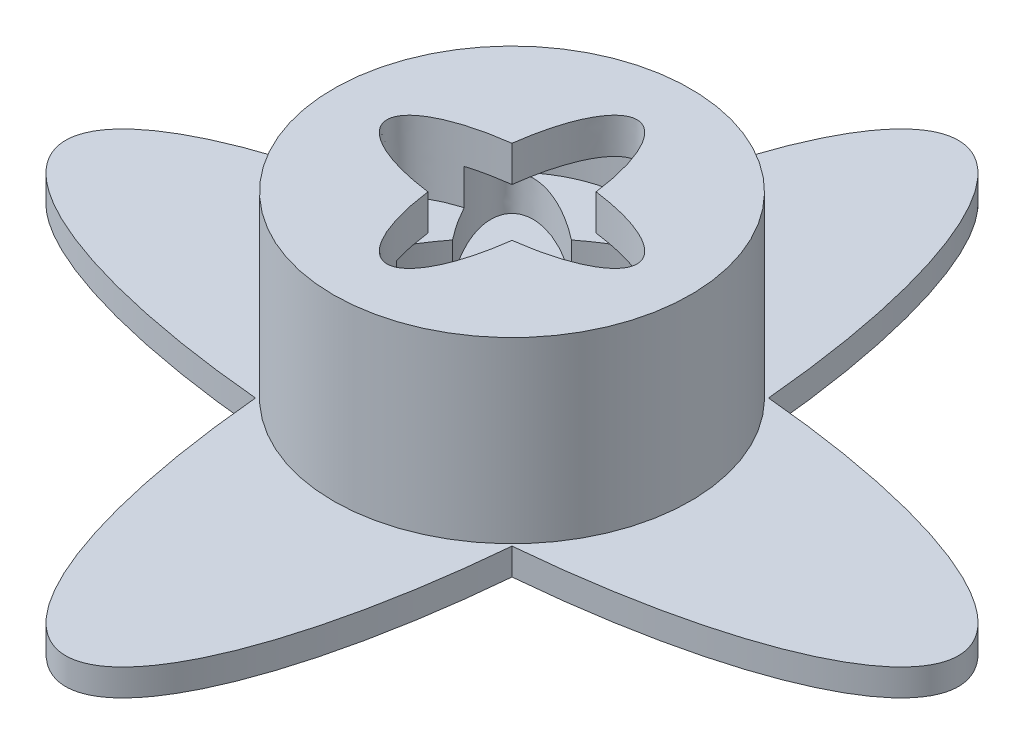
from build123d import *

# Parameters (mm, degrees)
BOSS_EXTRUDE1_DEPTH = 1.5
SKETCH2_R           = 10
BOSS_EXTRUDE2_DEPTH = 10
SKETCH3_R           = 2.5
CUT_EXTRUDE1_DEPTH  = 2.5
CUT_EXTRUDE2_DEPTH  = 4
CUT_EXTRUDE3_DEPTH  = 2
CUT_EXTRUDE4_DEPTH  = 2


with BuildPart() as part:
    # Sketch1 → Boss-Extrude1 (new body)
    with BuildSketch(Plane(origin=(0, 0, 0), x_dir=(1, 0, 0), z_dir=(0, 1, 0))):
        with BuildLine():
            add(Edge.make_bspline(
                [(7.183697139, 7.183697139), (0, 87.002554241), (-7.183697139, 7.183697139)],
                knots=[1.862253121, 1.862253121, 1.862253121, 4.420932186, 4.420932186, 4.420932186], degree=2, weights=[1, 0.287347886, 1]))
            add(Edge.make_bspline(
                [(-7.183697139, 7.183697139), (-87.002554241, 0), (-7.183697139, -7.183697139)],
                knots=[5.003845775, 5.003845775, 5.003845775, 7.562524839, 7.562524839, 7.562524839], degree=2, weights=[1, 0.287347886, 1]))
            add(Edge.make_bspline(
                [(-7.183697139, -7.183697139), (0, -87.002554241), (7.183697139, -7.183697139)],
                knots=[5.003845775, 5.003845775, 5.003845775, 7.562524839, 7.562524839, 7.562524839], degree=2, weights=[1, 0.287347886, 1]))
            add(Edge.make_bspline(
                [(7.183697139, -7.183697139), (87.002554241, 0), (7.183697139, 7.183697139)],
                knots=[1.862253121, 1.862253121, 1.862253121, 4.420932186, 4.420932186, 4.420932186], degree=2, weights=[1, 0.287347886, 1]))
        make_face()
    extrude(amount=BOSS_EXTRUDE1_DEPTH)

    # Sketch2 → Boss-Extrude2 (add)
    with BuildSketch(Plane(origin=(0, 1.5, 0), x_dir=(1, 0, 0), z_dir=(0, 1, 0))):
        Circle(SKETCH2_R)
    extrude(amount=BOSS_EXTRUDE2_DEPTH)

    # Sketch3 → Cut-Extrude1 (cut)
    with BuildSketch(Plane.XZ):
        Circle(SKETCH3_R)
    extrude(amount=-CUT_EXTRUDE1_DEPTH, mode=Mode.SUBTRACT)

    # Sketch4 → Cut-Extrude2 (cut)
    with BuildSketch(Plane(origin=(0, 11.5, 0), x_dir=(1, 0, 0), z_dir=(0, 1, 0))):
        with BuildLine():
            add(Edge.make_bspline(
                [(-2.354354779, -2.354354779), (0, -20.812496246), (2.354354779, -2.354354779)],
                knots=[5.055412921, 5.055412921, 5.055412921, 7.510957694, 7.510957694, 7.510957694], degree=2, weights=[1, 0.336336397, 1]))
            add(Edge.make_bspline(
                [(2.354354779, -2.354354779), (20.812496246, 0), (2.354354779, 2.354354779)],
                knots=[1.913820267, 1.913820267, 1.913820267, 4.36936504, 4.36936504, 4.36936504], degree=2, weights=[1, 0.336336397, 1]))
            add(Edge.make_bspline(
                [(2.354354779, 2.354354779), (0, 20.812496246), (-2.354354779, 2.354354779)],
                knots=[1.913820267, 1.913820267, 1.913820267, 4.36936504, 4.36936504, 4.36936504], degree=2, weights=[1, 0.336336397, 1]))
            add(Edge.make_bspline(
                [(-2.354354779, 2.354354779), (-20.812496246, 0), (-2.354354779, -2.354354779)],
                knots=[5.055412921, 5.055412921, 5.055412921, 7.510957694, 7.510957694, 7.510957694], degree=2, weights=[1, 0.336336397, 1]))
        make_face()
    extrude(amount=-CUT_EXTRUDE2_DEPTH, mode=Mode.SUBTRACT)

    # Sketch5 → Cut-Extrude3 (cut)
    with BuildSketch(Plane(origin=(0, 7.5, 0), x_dir=(1, 0, 0), z_dir=(0, 1, 0))):
        with BuildLine():
            ThreePointArc((7, 0), (6.467156728, 2.678784027), (4.949747468, 4.949747468))
            add(Edge.make_bspline(
                [(4.949747468, 4.949747468), (4.13981345, 5.759681487), (1.89338429, 4.571034031)],
                knots=[3.141592654, 3.141592654, 3.141592654, 4.000843717, 4.000843717, 4.000843717], degree=2, weights=[1, 0.909121791, 1]))
            add(Edge.make_bspline(
                [(1.89338429, 4.571034031), (1.145419674, 7), (0, 7)],
                knots=[2.282341591, 2.282341591, 2.282341591, 3.141592654, 3.141592654, 3.141592654], degree=2, weights=[1, 0.909121791, 1]))
            ThreePointArc((0, 7), (-2.678784027, 6.467156728), (-4.949747468, 4.949747468))
            add(Edge.make_bspline(
                [(-4.949747468, 4.949747468), (-5.759681487, 4.13981345), (-4.571034031, 1.89338429)],
                knots=[0, 0, 0, 0.859251063, 0.859251063, 0.859251063], degree=2, weights=[1, 0.909121791, 1]))
            add(Edge.make_bspline(
                [(-4.571034031, 1.89338429), (-7, 1.145419674), (-7, 0)],
                knots=[5.423934244, 5.423934244, 5.423934244, 6.283185307, 6.283185307, 6.283185307], degree=2, weights=[1, 0.909121791, 1]))
            ThreePointArc((-7, 0), (-6.467156728, -2.678784027), (-4.949747468, -4.949747468))
            add(Edge.make_bspline(
                [(-4.949747468, -4.949747468), (-4.13981345, -5.759681487), (-1.89338429, -4.571034031)],
                knots=[0, 0, 0, 0.859251063, 0.859251063, 0.859251063], degree=2, weights=[1, 0.909121791, 1]))
            add(Edge.make_bspline(
                [(-1.89338429, -4.571034031), (-1.145419674, -7), (0, -7)],
                knots=[5.423934244, 5.423934244, 5.423934244, 6.283185307, 6.283185307, 6.283185307], degree=2, weights=[1, 0.909121791, 1]))
            ThreePointArc((0, -7), (2.678784027, -6.467156728), (4.949747468, -4.949747468))
            add(Edge.make_bspline(
                [(4.949747468, -4.949747468), (5.759681487, -4.13981345), (4.571034031, -1.89338429)],
                knots=[3.141592654, 3.141592654, 3.141592654, 4.000843717, 4.000843717, 4.000843717], degree=2, weights=[1, 0.909121791, 1]))
            add(Edge.make_bspline(
                [(4.571034031, -1.89338429), (7, -1.145419674), (7, 0)],
                knots=[2.282341591, 2.282341591, 2.282341591, 3.141592654, 3.141592654, 3.141592654], degree=2, weights=[1, 0.909121791, 1]))
        make_face()
    extrude(amount=CUT_EXTRUDE3_DEPTH, mode=Mode.SUBTRACT)

    # Sketch6 → Cut-Extrude4 (cut)
    with BuildSketch(Plane(origin=(0, 7.5, 0), x_dir=(1, 0, 0), z_dir=(0, 1, 0))):
        with BuildLine():
            add(Edge.make_bspline(
                [(-3.329560459, 0), (-14.716657229, -14.716657229), (0, -3.329560459)],
                knots=[5.055412921, 5.055412921, 5.055412921, 7.510957694, 7.510957694, 7.510957694], degree=2, weights=[1, 0.336336397, 1]))
            add(Edge.make_bspline(
                [(0, -3.329560459), (14.716657229, -14.716657229), (3.329560459, 0)],
                knots=[1.913820267, 1.913820267, 1.913820267, 4.36936504, 4.36936504, 4.36936504], degree=2, weights=[1, 0.336336397, 1]))
            add(Edge.make_bspline(
                [(3.329560459, 0), (14.716657229, 14.716657229), (0, 3.329560459)],
                knots=[1.913820267, 1.913820267, 1.913820267, 4.36936504, 4.36936504, 4.36936504], degree=2, weights=[1, 0.336336397, 1]))
            add(Edge.make_bspline(
                [(0, 3.329560459), (-14.716657229, 14.716657229), (-3.329560459, 0)],
                knots=[5.055412921, 5.055412921, 5.055412921, 7.510957694, 7.510957694, 7.510957694], degree=2, weights=[1, 0.336336397, 1]))
        make_face()
    extrude(amount=-CUT_EXTRUDE4_DEPTH, mode=Mode.SUBTRACT)


solid = part.part
